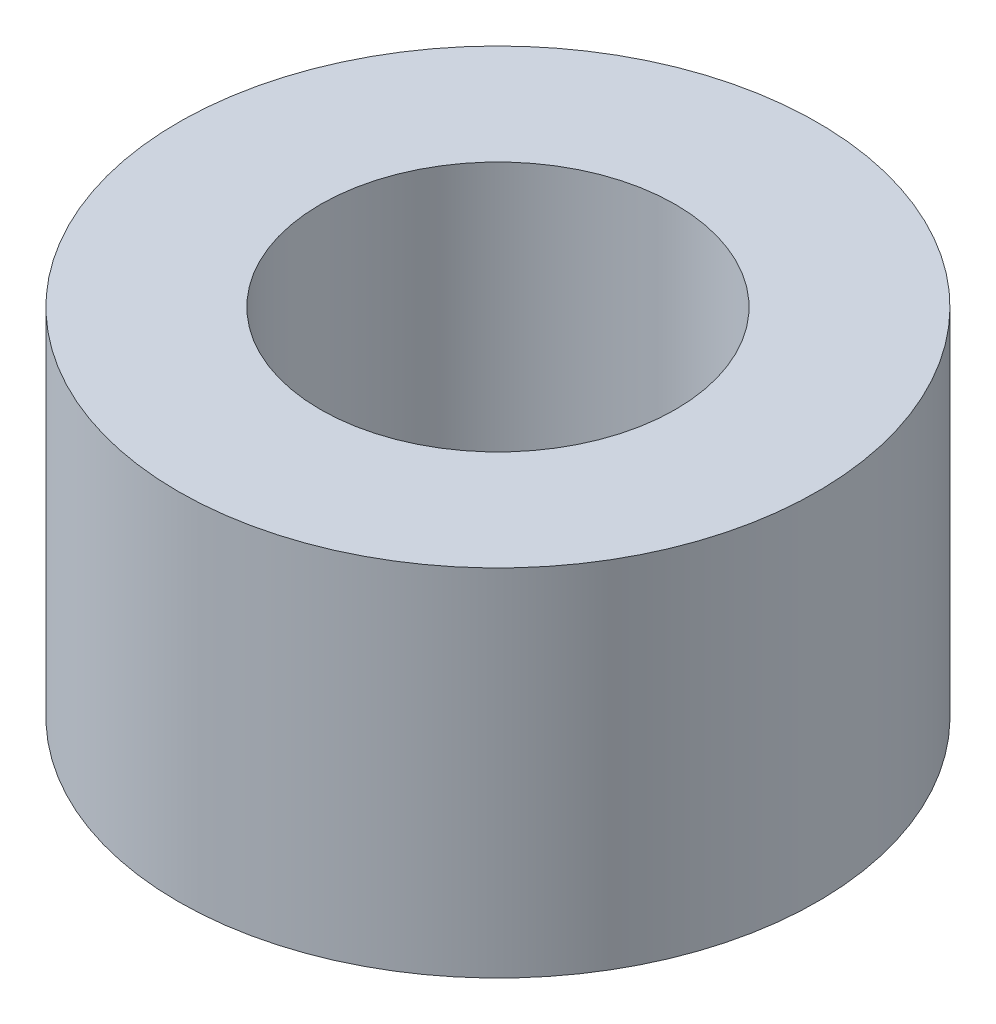
from build123d import *

# Parameters (mm, degrees)
SKETCH1_R           = 2.25
SKETCH1_R_2         = 1.25
BOSS_EXTRUDE1_DEPTH = 2.5


with BuildPart() as part:
    # Sketch1 → Boss-Extrude1 (new body)
    with BuildSketch(Plane(origin=(0, 0, 0), x_dir=(1, 0, 0), z_dir=(0, 1, 0))):
        Circle(SKETCH1_R)
        Circle(SKETCH1_R_2, mode=Mode.SUBTRACT)
    extrude(amount=BOSS_EXTRUDE1_DEPTH)


solid = part.part
